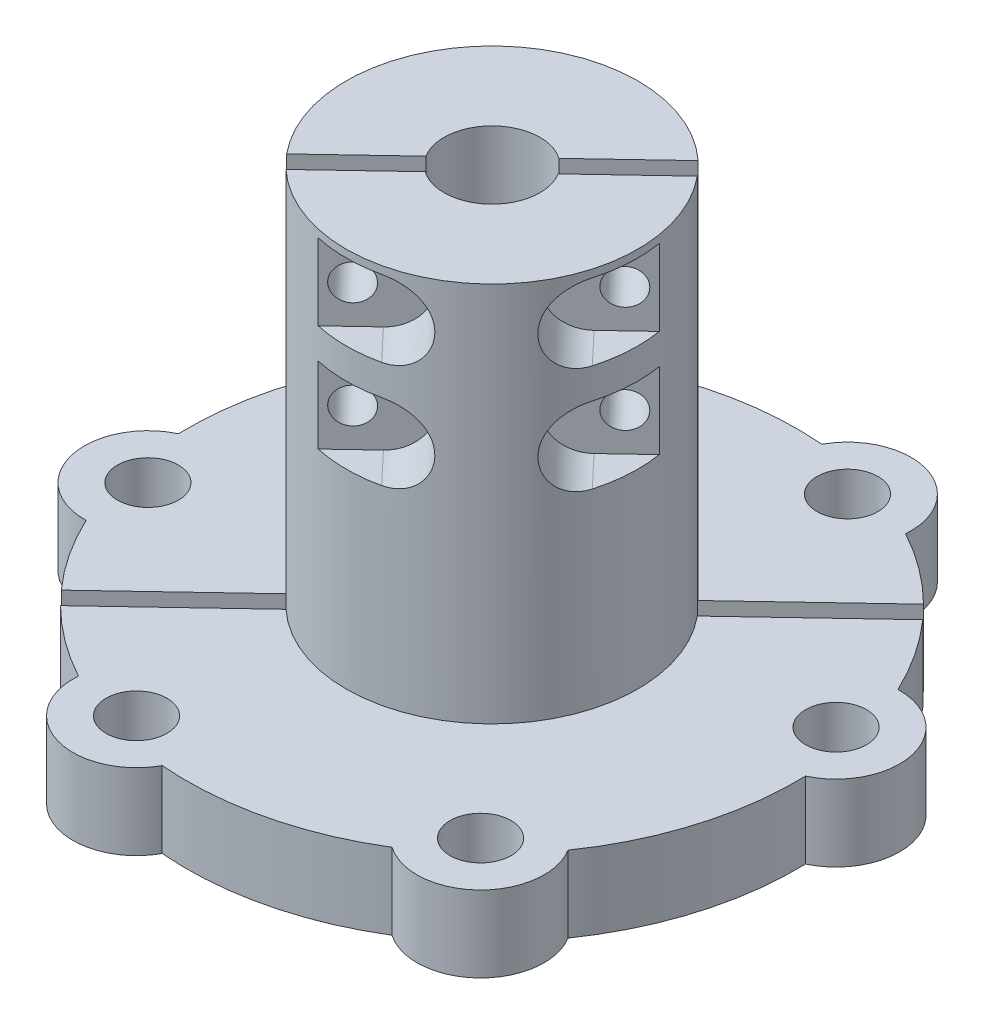
from build123d import *

# Parameters (mm, degrees)
SKETCH1_R                = 29.36875
SKETCH1_R_2              = 4
BOSS_EXTRUDE1_DEPTH      = 6.35
SKETCH3_R                = 12.1539
SKETCH3_R_2              = 4
BOSS_EXTRUDE2_DEPTH      = 31.75
SKETCH4_R                = 51.921805426
CUT_EXTRUDE1_DEPTH       = 7.35
SKETCH5_R                = 2.54
CUT_EXTRUDE2_DEPTH       = 7.35
SKETCH6_R                = 9.525
CUT_EXTRUDE3_DEPTH       = 12.7
SLOT_DEPTH               = 39.1
SKETCH8_R                = 1.4732
NO4_40_HOLES_DEPTH       = 78.297408603
SKETCH9_R                = 2.413
NO4_40_COUNTERBORE_DEPTH = 30.48
NO4_40_NUT_SLOTS_DEPTH   = 30.48


with BuildPart() as part:
    # Sketch1 → Boss-Extrude1 (new body)
    with BuildSketch(Plane(origin=(0, 0, 0), x_dir=(1, 0, 0), z_dir=(0, 1, 0))):
        Circle(SKETCH1_R)
        Circle(SKETCH1_R_2, mode=Mode.SUBTRACT)
    extrude(amount=BOSS_EXTRUDE1_DEPTH)

    # Sketch3 → Boss-Extrude2 (add)
    with BuildSketch(Plane(origin=(0, 6.35, 0), x_dir=(1, 0, 0), z_dir=(0, 1, 0))):
        Circle(SKETCH3_R)
        Circle(SKETCH3_R_2, mode=Mode.SUBTRACT)
    extrude(amount=BOSS_EXTRUDE2_DEPTH)

    # Sketch4 → Cut-Extrude1 (cut, through all)
    with BuildSketch(Plane(origin=(0, 6.35, 0), x_dir=(1, 0, 0), z_dir=(0, 1, 0))):
        Circle(SKETCH4_R)
        with BuildLine():
            ThreePointArc((25.42076074, 0.709944805), (28.324858383, 6.735804714), (23.019076794, 10.809310883))
            ThreePointArc((23.019076794, 10.809310883), (18.484111888, 17.465872608), (12.0949106, 22.370342774))
            ThreePointArc((12.0949106, 22.370342774), (8.328217656, 27.897294332), (2.14806083, 25.33978952))
            ThreePointArc((2.14806083, 25.33978952), (-5.884518791, 24.740483763), (-13.326739439, 21.659111573))
            ThreePointArc((-13.326739439, 21.659111573), (-19.996545459, 21.160255493), (-20.871481236, 14.529293488))
            ThreePointArc((-20.871481236, 14.529293488), (-24.368348322, 7.273424109), (-25.420701023, -0.712079861))
            ThreePointArc((-25.420701023, -0.712079861), (-28.324292628, -6.738183701), (-23.018168837, -10.811244223))
            ThreePointArc((-23.018168837, -10.811244223), (-18.483144187, -17.466896668), (-12.09431069, -22.370667115))
            ThreePointArc((-12.09431069, -22.370667115), (-8.327541601, -27.899303758), (-2.146612242, -25.339912275))
            ThreePointArc((-2.146612242, -25.339912275), (5.884518724, -24.740483779), (13.325501128, -21.659873451))
            ThreePointArc((13.325501128, -21.659873451), (19.996846315, -21.162354177), (20.871091496, -14.529853337))
            ThreePointArc((20.871091496, -14.529853337), (24.367945291, -7.274774259), (25.42076074, 0.709944805))
        make_face(mode=Mode.SUBTRACT)
    extrude(amount=-CUT_EXTRUDE1_DEPTH, mode=Mode.SUBTRACT)

    # Sketch5 → Cut-Extrude2 (cut, through all)
    with BuildSketch(Plane(origin=(0, 6.35, 0), x_dir=(1, 0, 0), z_dir=(0, 1, 0))):
        with Locations((-23.165997257, -5.511055375)):
            Circle(SKETCH5_R)
        with Locations((-6.811011525, -22.818556609)):
            Circle(SKETCH5_R)
        with Locations((16.355217086, -17.308474104)):
            Circle(SKETCH5_R)
        with Locations((23.166459964, 5.509109636)):
            Circle(SKETCH5_R)
        with Locations((6.811474232, 22.81661087)):
            Circle(SKETCH5_R)
        with Locations((-16.354754378, 17.306528364)):
            Circle(SKETCH5_R)
    extrude(amount=-CUT_EXTRUDE2_DEPTH, mode=Mode.SUBTRACT)

    # Sketch6 → Cut-Extrude3 (cut)
    with BuildSketch(Plane.XZ):
        with Locations((-8.2e-08, 1.9e-08)):
            Circle(SKETCH6_R)
    extrude(amount=-CUT_EXTRUDE3_DEPTH, mode=Mode.SUBTRACT)

    # Sketch7 → Slot (cut, through all)
    with BuildSketch(Plane.XZ):
        with BuildLine():
            Line((-23.884082698, 21.478515658), (22.794718016, -22.631325011))
            ThreePointArc((22.794718016, -22.631325011), (23.347000893, -22.061133029), (23.885025086, -21.477467678))
            Line((23.885025086, -21.477467678), (-22.793725002, 22.632325151))
            ThreePointArc((-22.793725002, 22.632325151), (-23.346032897, 22.062157402), (-23.884082698, 21.478515658))
        make_face()
    extrude(amount=-SLOT_DEPTH, mode=Mode.SUBTRACT)

    # Sketch8 → No4-40 Holes (cut, through all)
    with BuildSketch(Plane(origin=(-25.622327145, 0, -27.114573176), x_dir=(-0.726824197, 0, 0.686823548), z_dir=(-0.686823548, 0, -0.726824197))):
        with Locations((8.02410922, 34.29)):
            Circle(SKETCH8_R)
        with Locations((8.02410922, 25.4)):
            Circle(SKETCH8_R)
        with Locations((-8.02410922, 34.29)):
            Circle(SKETCH8_R)
        with Locations((-8.02410922, 25.4)):
            Circle(SKETCH8_R)
    extrude(amount=-NO4_40_HOLES_DEPTH, mode=Mode.SUBTRACT)

    # Sketch9 → No4-40 Counterbore (cut)
    with BuildSketch(Plane(origin=(-25.622327145, 0, -27.114573176), x_dir=(-0.726824197, 0, 0.686823548), z_dir=(-0.686823548, 0, -0.726824197))):
        with Locations((8.02410922, 25.4)):
            Circle(SKETCH9_R)
        with Locations((8.02410922, 34.29)):
            Circle(SKETCH9_R)
        with Locations((-8.02410922, 25.4)):
            Circle(SKETCH9_R)
        with Locations((-8.02410922, 34.29)):
            Circle(SKETCH9_R)
    extrude(amount=-NO4_40_COUNTERBORE_DEPTH, mode=Mode.SUBTRACT)

    # Sketch10 → No4-40 Nut Slots (cut)
    with BuildSketch(Plane(origin=(25.623294846, 0, 27.115597236), x_dir=(0.726824197, 0, -0.686823548), z_dir=(0.686823548, 0, 0.726824197))):
        with BuildLine():
            Line((6.210112817, 37.465), (22.611534214, 37.465))
            Line((22.611534214, 37.465), (22.611534214, 31.115))
            Line((22.611534214, 31.115), (6.210112817, 31.115))
            ThreePointArc((6.210112817, 31.115), (3.035112817, 34.29), (6.210112817, 37.465))
        make_face()
        with BuildLine():
            Line((6.210112817, 28.575), (22.611534214, 28.575))
            Line((22.611534214, 28.575), (22.611534214, 22.225))
            Line((22.611534214, 22.225), (6.210112817, 22.225))
            ThreePointArc((6.210112817, 22.225), (3.035112817, 25.4), (6.210112817, 28.575))
        make_face()
        with BuildLine():
            Line((-22.611534214, 22.225), (-6.210112817, 22.225))
            ThreePointArc((-6.210112817, 22.225), (-3.035112817, 25.4), (-6.210112817, 28.575))
            Line((-6.210112817, 28.575), (-22.611534214, 28.575))
            Line((-22.611534214, 28.575), (-22.611534214, 22.225))
        make_face()
        with BuildLine():
            Line((-22.611534214, 31.115), (-22.611534214, 37.465))
            Line((-22.611534214, 37.465), (-6.210112817, 37.465))
            ThreePointArc((-6.210112817, 37.465), (-3.035112817, 34.29), (-6.210112817, 31.115))
            Line((-6.210112817, 31.115), (-22.611534214, 31.115))
        make_face()
    extrude(amount=-NO4_40_NUT_SLOTS_DEPTH, mode=Mode.SUBTRACT)


solid = part.part
